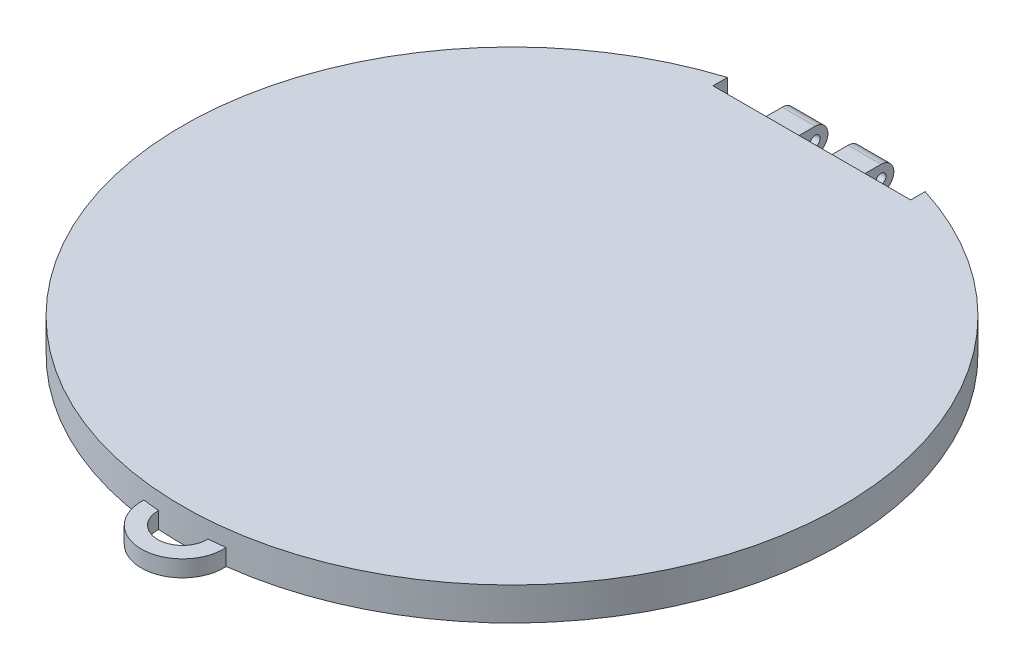
from build123d import *

# Parameters (mm, degrees)
SKETCH1_R            = 100
BOSS_EXTRUDE1_DEPTH  = 10
SKETCH3_W            = 60
SKETCH3_H            = 18
CUT_EXTRUDE1_DEPTH   = 142.774468788
SKETCH4_W            = 10
SKETCH4_H            = 5.88
BOSS_EXTRUDE2_DEPTH  = 2.12
SKETCH5_R            = 3.88
BOSS_EXTRUDE3_DEPTH  = 10
SKETCH6_R            = 3.88
BOSS_EXTRUDE4_DEPTH  = 10
SKETCH7_R            = 1.5
CUT_EXTRUDE2_DEPTH   = 154.436986415
BOSS_EXTRUDE5_REACH  = 219.799
SKETCH8_W            = 10
SKETCH8_H            = 5.88
BOSS_EXTRUDE6_REACH  = 219.799
SKETCH9_W            = 10
SKETCH9_H            = 5.88
BOSS_EXTRUDE8_DEPTH  = 3
CUT_EXTRUDE3_DEPTH   = 3
SKETCH22_R           = 12.5
SKETCH22_R_2         = 7.5
BOSS_EXTRUDE10_DEPTH = 5


with BuildPart() as part:
    # Sketch1 → Boss-Extrude1 (new body)
    with BuildSketch(Plane(origin=(0, 0, 0), x_dir=(1, 0, 0), z_dir=(0, 1, 0))):
        with Locations(Location((0, 0, 0), (0, 0, 270))):
            Circle(SKETCH1_R)
    extrude(amount=-BOSS_EXTRUDE1_DEPTH)

    # Sketch3 → Cut-Extrude1 (cut, through all)
    with BuildSketch(Plane(origin=(0, 0, 0), x_dir=(1, 0, 0), z_dir=(0, 1, 0))):
        with Locations((0, 100)):
            Rectangle(SKETCH3_W, SKETCH3_H)
    extrude(amount=-CUT_EXTRUDE1_DEPTH, mode=Mode.SUBTRACT)

    # Sketch4 → Boss-Extrude2 (add)
    with BuildSketch(Plane(origin=(0, 0, -91), x_dir=(-1, 0, 0), z_dir=(0, 0, -1))):
        with Locations((10, -7.06)):
            Rectangle(SKETCH4_W, SKETCH4_H)
        with Locations((-10, -7.06)):
            Rectangle(SKETCH4_W, SKETCH4_H)
    extrude(amount=BOSS_EXTRUDE2_DEPTH)


with BuildPart() as body_2:
    # Sketch5 → Boss-Extrude3 (new body)
    with BuildSketch(Plane(origin=(-5, 0, 0), x_dir=(0, 0, -1), z_dir=(1, 0, 0))):
        with Locations((97, -8)):
            Circle(SKETCH5_R)
    extrude(amount=-BOSS_EXTRUDE3_DEPTH)


with BuildPart() as body_3:
    # Sketch6 → Boss-Extrude4 (new body)
    with BuildSketch(Plane(origin=(15, 0, 0), x_dir=(0, 0, -1), z_dir=(1, 0, 0))):
        with Locations(Location((97, -8, 0), (0, 0, 90))):
            Circle(SKETCH6_R)
    extrude(amount=-BOSS_EXTRUDE4_DEPTH)


with BuildPart() as cut_extrude2_tool:
    # Sketch7 → Cut-Extrude2 (new, through all)
    with BuildSketch(Plane(origin=(15, 0, 0), x_dir=(0, 0, -1), z_dir=(1, 0, 0))):
        with Locations(Location((97, -8, 0), (0, 0, 90))):
            Circle(SKETCH7_R)
    extrude(amount=-CUT_EXTRUDE2_DEPTH)


with BuildPart() as body_2_1:
    add(body_2.part)

    # Cut-Extrude2: cut by cut_extrude2_tool
    add(cut_extrude2_tool.part, mode=Mode.SUBTRACT)

    # Sketch8 → Boss-Extrude5 (add, up to next)
    with BuildSketch(Plane(origin=(0, 0, -93.12), x_dir=(-1, 0, 0), z_dir=(0, 0, -1)), mode=Mode.PRIVATE) as boss_extrude5_sk1:
        with Locations((10, -7.06)):
            Rectangle(SKETCH8_W, SKETCH8_H)
    boss_extrude5_tool1 = extrude(boss_extrude5_sk1.sketch, amount=BOSS_EXTRUDE5_REACH, mode=Mode.PRIVATE) - body_2_1.part

    add(part.part)  # Boss-Extrude5 merges part
    add(boss_extrude5_tool1.solids().sort_by_distance((-10, -7.06, -93.12))[0])
    add(boss_extrude5_tool1.solids().sort_by_distance((-10, -7.06, -93.12))[1])


with BuildPart() as body_3_1:
    add(body_3.part)

    # Cut-Extrude2: cut by cut_extrude2_tool
    add(cut_extrude2_tool.part, mode=Mode.SUBTRACT)

    # Sketch9 → Boss-Extrude6 (add, up to next)
    with BuildSketch(Plane(origin=(0, 0, -93.12), x_dir=(-1, 0, 0), z_dir=(0, 0, -1)), mode=Mode.PRIVATE) as boss_extrude6_sk1:
        with Locations((-10, -7.06)):
            Rectangle(SKETCH9_W, SKETCH9_H)
    boss_extrude6_tool1 = extrude(boss_extrude6_sk1.sketch, amount=BOSS_EXTRUDE6_REACH, mode=Mode.PRIVATE) - body_3_1.part

    add(body_2_1.part)  # Boss-Extrude6 merges body 2
    add(boss_extrude6_tool1.solids().sort_by_distance((10, -7.06, -93.12))[0])
    add(boss_extrude6_tool1.solids().sort_by_distance((10, -7.06, -93.12))[1])

    # Sketch12 → Boss-Extrude8 (add)
    with BuildSketch(Plane(origin=(0, -10, 0), x_dir=(-1, 0, 0), z_dir=(0, -1, 0))):
        with BuildLine():
            Line((30, 95.393920142), (30, 91))
            Line((30, 91), (-30, 91))
            Line((-30, 91), (-30, 95.393920142))
            ThreePointArc((-30, 95.393920142), (0, -100), (30, 95.393920142))
        make_face()
    extrude(amount=BOSS_EXTRUDE8_DEPTH)

    # Sketch13 → Cut-Extrude3 (cut)
    with BuildSketch(Plane(origin=(0, 0, 0), x_dir=(1, 0, 0), z_dir=(0, 1, 0))):
        with BuildLine():
            Line((-30, 95.393920142), (-30, 91))
            Line((-30, 91), (30, 91))
            Line((30, 91), (30, 95.393920142))
            ThreePointArc((30, 95.393920142), (0, -100), (-30, 95.393920142))
        make_face()
    extrude(amount=-CUT_EXTRUDE3_DEPTH, mode=Mode.SUBTRACT)

    # Sketch22 → Boss-Extrude10 (add)
    with BuildSketch(Plane(origin=(0, -13, 0), x_dir=(-1, 0, 0), z_dir=(0, -1, 0))):
        with Locations((0, -100)):
            Circle(SKETCH22_R)
        with Locations((0, -100)):
            Circle(SKETCH22_R_2, mode=Mode.SUBTRACT)
    extrude(amount=-BOSS_EXTRUDE10_DEPTH)


solid = body_3_1.part
